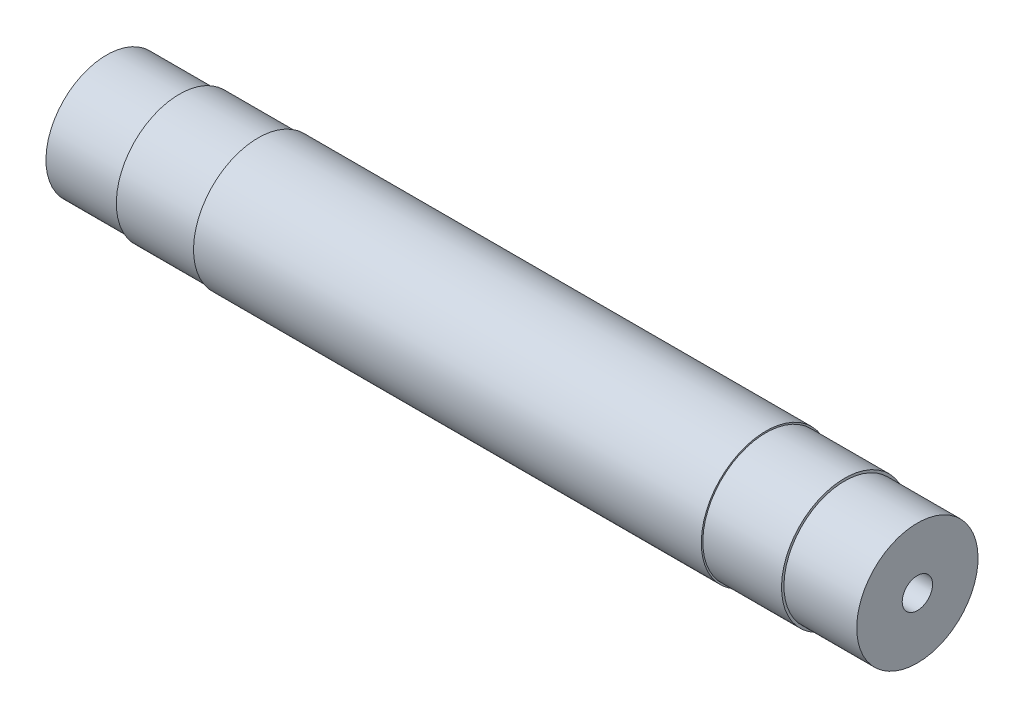
from build123d import *

# Parameters (mm, degrees)
HOLE_WIZARD_M61_D     = 5
HOLE_WIZARD_M61_DEPTH = 27
HOLE_WIZARD_M61_TIP   = 1.502151548


with BuildPart() as part:
    # Эскиз1 → Повернуть1 (revolve)
    with BuildSketch(Plane.XY):
        Polygon((0, 0), (0, 10.65), (-41.861372681, 10.65), (-41.861372681, 10.4), (-54.841568778, 10.4), (-54.841568778, 10), (-66.841568778, 10), (-66.841568778, 0), align=None)
    revolve(axis=Axis((-66.841568778, 0, 0), (1, 0, 0)))

    # Отверстие обработанное метчиком M61
    with Locations(Plane.ZY.offset(66.841568778)):
        with Locations((0, 0)):
            Hole(HOLE_WIZARD_M61_D / 2, depth=HOLE_WIZARD_M61_DEPTH)
            with Locations((0, 0, -(HOLE_WIZARD_M61_DEPTH + HOLE_WIZARD_M61_TIP / 2))):  # 118° drill point
                Cone(0, HOLE_WIZARD_M61_D / 2, HOLE_WIZARD_M61_TIP, mode=Mode.SUBTRACT)

    # Зеркальное отражение1: part across plane


with BuildPart() as part_1:
    add(part.part)
    add(part.part.mirror(Plane.ZY))


solid = part_1.part
